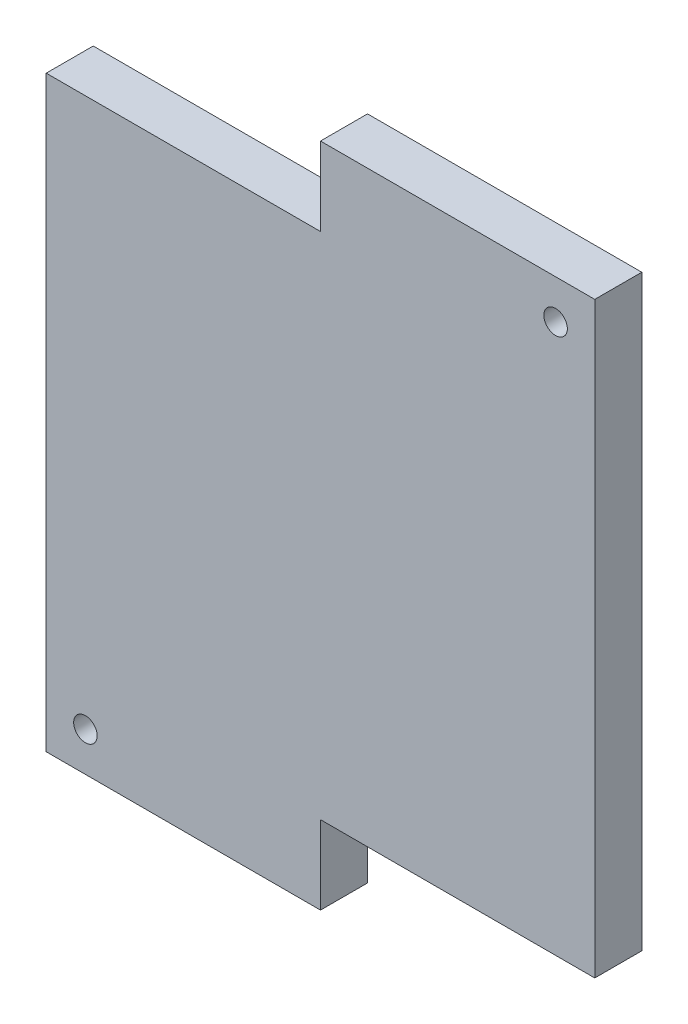
from build123d import *

# Parameters (mm, degrees)
SKETCH1_R           = 1.5
BOSS_EXTRUDE1_DEPTH = 6


with BuildPart() as part:
    # Sketch1 → Boss-Extrude1 (new body)
    with BuildSketch(Plane.XY):
        Polygon((0, 0), (35, 0), (35, 10), (70, 10), (70, 85), (35, 85), (35, 75), (0, 75), align=None)
        with Locations((65, 80)):
            Circle(SKETCH1_R, mode=Mode.SUBTRACT)
        with Locations((5, 5)):
            Circle(SKETCH1_R, mode=Mode.SUBTRACT)
    extrude(amount=BOSS_EXTRUDE1_DEPTH)


solid = part.part
